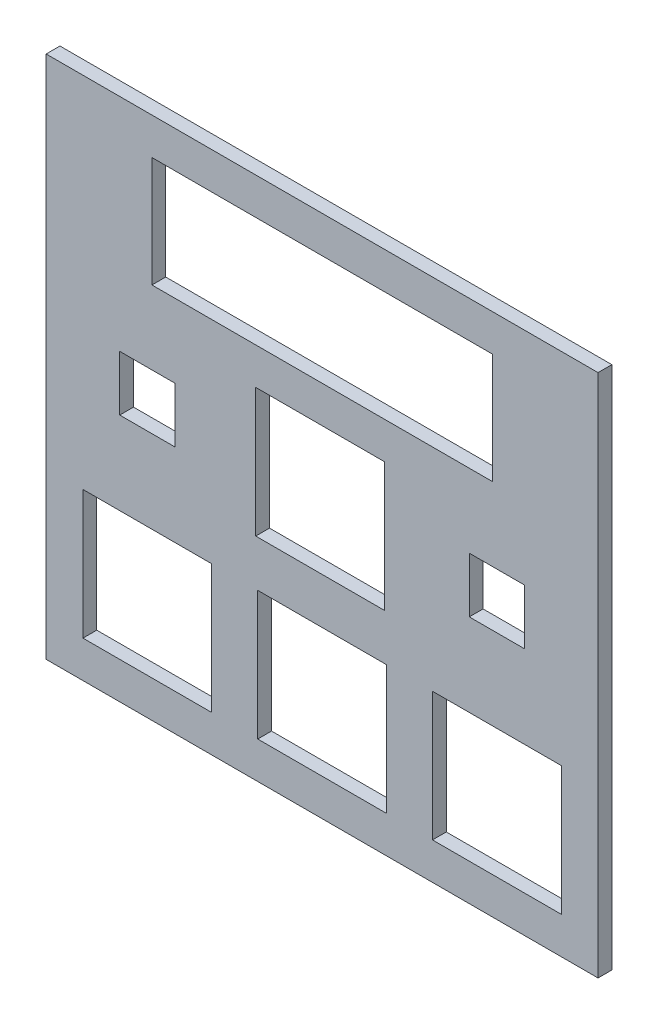
from build123d import *

# Parameters (mm, degrees)
SKETCH1_W           = 60
SKETCH1_H           = 57
SKETCH1_W_2         = 14
SKETCH1_H_2         = 14
SKETCH1_W_3         = 37
SKETCH1_H_3         = 12
SKETCH1_W_4         = 6
SKETCH1_H_4         = 6
BOSS_EXTRUDE1_DEPTH = 1.5


with BuildPart() as part:
    # Sketch1 → Boss-Extrude1 (new body)
    with BuildSketch(Plane.XY):
        with Locations((0.299968287, -12.658536585)):
            Rectangle(SKETCH1_W, SKETCH1_H)
        with Locations((-18.700031713, -30.158536585)):
            Rectangle(SKETCH1_W_2, SKETCH1_H_2, mode=Mode.SUBTRACT)
        with Locations((0.299968287, -30.158536585)):
            Rectangle(SKETCH1_W_2, SKETCH1_H_2, mode=Mode.SUBTRACT)
        with Locations((19.299968287, -30.158536585)):
            Rectangle(SKETCH1_W_2, SKETCH1_H_2, mode=Mode.SUBTRACT)
        with Locations((0.085273165, -11.158536585)):
            Rectangle(SKETCH1_W_2, SKETCH1_H_2, mode=Mode.SUBTRACT)
        with Locations((0.299968287, 5.841463415)):
            Rectangle(SKETCH1_W_3, SKETCH1_H_3, mode=Mode.SUBTRACT)
        with Locations((-18.700031713, -11.158536585)):
            Rectangle(SKETCH1_W_4, SKETCH1_H_4, mode=Mode.SUBTRACT)
        with Locations((19.299968287, -11.158536585)):
            Rectangle(SKETCH1_W_4, SKETCH1_H_4, mode=Mode.SUBTRACT)
    extrude(amount=BOSS_EXTRUDE1_DEPTH)


solid = part.part
